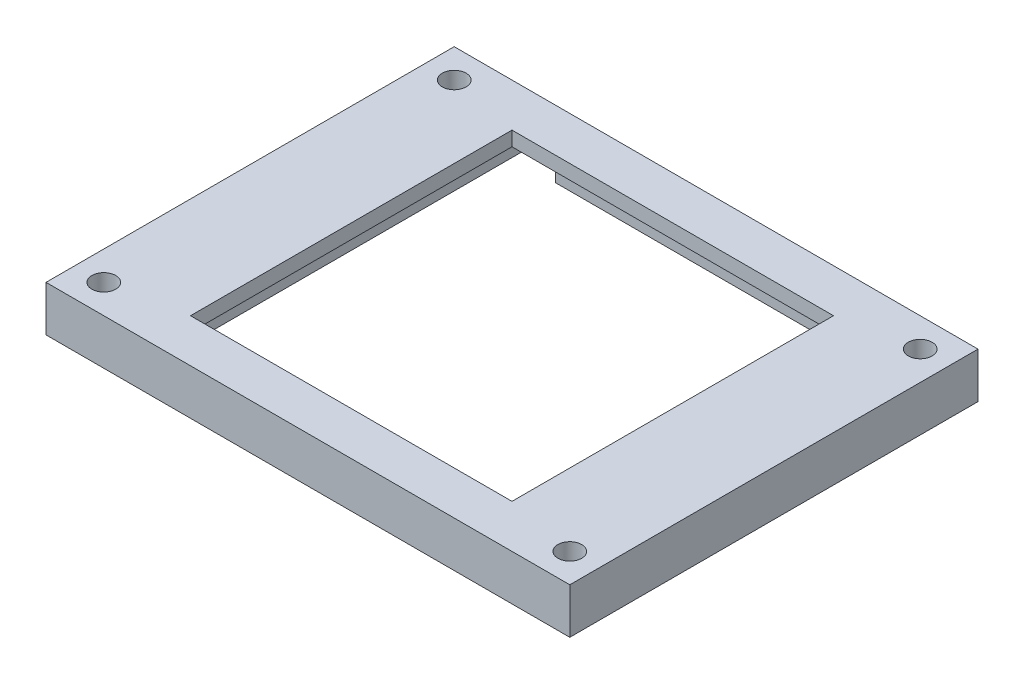
from build123d import *

# Parameters (mm, degrees)
SKETCH1_W           = 56.5
SKETCH1_H           = 56.5
SKETCH1_W_2         = 50.5
SKETCH1_H_2         = 50.5
SKETCH1_R           = 1.65
BOSS_EXTRUDE1_DEPTH = 8.6
SKETCH2_W           = 50.5
SKETCH2_H           = 50.5
SKETCH2_W_2         = 44.5
SKETCH2_H_2         = 44.5
BOSS_EXTRUDE2_DEPTH = 2
BOSS_EXTRUDE3_START = 6.6
SKETCH4_W           = 50.5
SKETCH4_H           = 50.5
SKETCH4_W_2         = 44.5
SKETCH4_H_2         = 44.5
BOSS_EXTRUDE3_DEPTH = 2
CUT_EXTRUDE1_START  = 2
SKETCH5_W           = 6
SKETCH5_H           = 17.961455198
CUT_EXTRUDE1_DEPTH  = 4.6
SKETCH6_W           = 87.3205389
SKETCH6_H           = 82.15723747
CUT_EXTRUDE2_DEPTH  = 2.3
CUT_EXTRUDE4_DEPTH  = 10
SKETCH8_W           = 8
SKETCH8_H           = 40.5
BOSS_EXTRUDE4_DEPTH = 6.3


with BuildPart() as part:
    # Sketch1 → Boss-Extrude1 (new body)
    with BuildSketch(Plane(origin=(0, 0, 0), x_dir=(1, 0, 0), z_dir=(0, 1, 0))):
        Rectangle(SKETCH1_W, SKETCH1_H)
        Rectangle(SKETCH1_W_2, SKETCH1_H_2, mode=Mode.SUBTRACT)
        Polygon((-28.25, -28.25), (-28.25, -12.25), (-36.25, -20.25), (-36.25, -30.25), (-32.25, -34.25), (-24.25, -34.25), (-18.25, -28.25), align=None)
        with Locations((-32.25, -24.25)):
            Circle(SKETCH1_R, mode=Mode.SUBTRACT)
        Polygon((28.25, -28.25), (18.25, -28.25), (24.25, -34.25), (32.25, -34.25), (36.25, -30.25), (36.25, -20.25), (28.25, -12.25), align=None)
        with Locations((32.25, -24.25)):
            Circle(SKETCH1_R, mode=Mode.SUBTRACT)
        Polygon((24.25, 34.25), (18.25, 28.25), (28.25, 28.25), (28.25, 12.25), (36.25, 20.25), (36.25, 30.25), (32.25, 34.25), align=None)
        with Locations((32.25, 24.25)):
            Circle(SKETCH1_R, mode=Mode.SUBTRACT)
        Polygon((-36.25, 20.25), (-28.25, 12.25), (-28.25, 28.25), (-18.25, 28.25), (-24.25, 34.25), (-32.25, 34.25), (-36.25, 30.25), align=None)
        with Locations((-32.25, 24.25)):
            Circle(SKETCH1_R, mode=Mode.SUBTRACT)
    extrude(amount=BOSS_EXTRUDE1_DEPTH)

    # Sketch2 → Boss-Extrude2 (add)
    with BuildSketch(Plane(origin=(0, 0, 0), x_dir=(1, 0, 0), z_dir=(0, 1, 0))):
        Rectangle(SKETCH2_W, SKETCH2_H)
        Rectangle(SKETCH2_W_2, SKETCH2_H_2, mode=Mode.SUBTRACT)
    extrude(amount=BOSS_EXTRUDE2_DEPTH)

    # Sketch4 → Boss-Extrude3 (add)
    with BuildSketch(Plane(origin=(0, 0, 0), x_dir=(1, 0, 0), z_dir=(0, 1, 0)).offset(BOSS_EXTRUDE3_START)):
        Rectangle(SKETCH4_W, SKETCH4_H)
        Rectangle(SKETCH4_W_2, SKETCH4_H_2, mode=Mode.SUBTRACT)
    extrude(amount=BOSS_EXTRUDE3_DEPTH)

    # Sketch5 → Cut-Extrude1 (cut)
    with BuildSketch(Plane(origin=(0, 0, 0), x_dir=(1, 0, 0), z_dir=(0, 1, 0)).offset(CUT_EXTRUDE1_START)):
        with Locations((-22.25, 28.869783692)):
            Rectangle(SKETCH5_W, SKETCH5_H)
        with Locations((22.25, 28.869783692)):
            Rectangle(SKETCH5_W, SKETCH5_H)
    extrude(amount=CUT_EXTRUDE1_DEPTH, mode=Mode.SUBTRACT)

    # Sketch6 → Cut-Extrude2 (cut)
    with BuildSketch(Plane.XZ):
        with Locations((1.898272585, -1.518618068)):
            Rectangle(SKETCH6_W, SKETCH6_H)
    extrude(amount=-CUT_EXTRUDE2_DEPTH, mode=Mode.SUBTRACT)

    # Sketch7 → Cut-Extrude4 (cut)
    with BuildSketch(Plane(origin=(0, 8.6, 0), x_dir=(1, 0, 0), z_dir=(0, 1, 0))):
        Polygon((-36.25, -30.25), (-36.25, -28.25), (-40.881768663, -28.25), (-40.881768663, -34.995320637), (0, -34.995320637), (0, -28.25), (-18.25, -28.25), (-24.25, -34.25), (-32.25, -34.25), align=None)
        Polygon((18.25, -28.25), (0, -28.25), (0, -34.995320637), (39.184342226, -34.995320637), (39.184342226, -28.25), (36.25, -28.25), (36.25, -30.25), (32.25, -34.25), (24.25, -34.25), align=None)
        Polygon((36.25, 20.25), (36.25, -20.25), (28.25, -12.25), (28.25, 12.25), align=None)
        Polygon((-36.25, 20.25), (-36.25, -20.25), (-28.25, -12.25), (-28.25, 12.25), align=None)
        Polygon((-36.25, 30.25), (-36.25, 28.25), (-18.25, 28.25), (-24.25, 34.25), (-32.25, 34.25), align=None)
        Polygon((-38.207606214, 28.25), (-36.25, 28.25), (-36.25, 30.25), (-32.25, 34.25), (-24.25, 34.25), (-18.25, 28.25), (0, 28.25), (0, 36.724555445), (-38.207606214, 36.724555445), align=None)
        Polygon((28.25, 12.25), (36.25, 20.25), (28.25, 20.25), align=None)
        Polygon((28.25, -20.25), (36.25, -20.25), (28.25, -12.25), align=None)
        Polygon((-18.25, -28.25), (-36.25, -28.25), (-36.25, -30.25), (-32.25, -34.25), (-24.25, -34.25), align=None)
        Polygon((-28.25, -12.25), (-36.25, -20.25), (-28.25, -20.25), align=None)
        Polygon((-28.25, 20.25), (-36.25, 20.25), (-28.25, 12.25), align=None)
        Polygon((24.25, 34.25), (18.25, 28.25), (36.25, 28.25), (36.25, 30.25), (32.25, 34.25), align=None)
        Polygon((0, 36.724555445), (0, 28.25), (18.25, 28.25), (24.25, 34.25), (32.25, 34.25), (36.25, 30.25), (36.25, 28.25), (40.981198071, 28.25), (40.981198071, 36.724555445), align=None)
        Polygon((36.25, -28.25), (18.25, -28.25), (24.25, -34.25), (32.25, -34.25), (36.25, -30.25), align=None)
    extrude(amount=-CUT_EXTRUDE4_DEPTH, mode=Mode.SUBTRACT)

    # Sketch8 → Boss-Extrude4 (add)
    with BuildSketch(Plane(origin=(0, 8.6, 0), x_dir=(1, 0, 0), z_dir=(0, 1, 0))):
        with Locations((-32.25, 0)):
            Rectangle(SKETCH8_W, SKETCH8_H)
        with Locations((32.25, 0)):
            Rectangle(SKETCH8_W, SKETCH8_H)
    extrude(amount=-BOSS_EXTRUDE4_DEPTH)


solid = part.part
